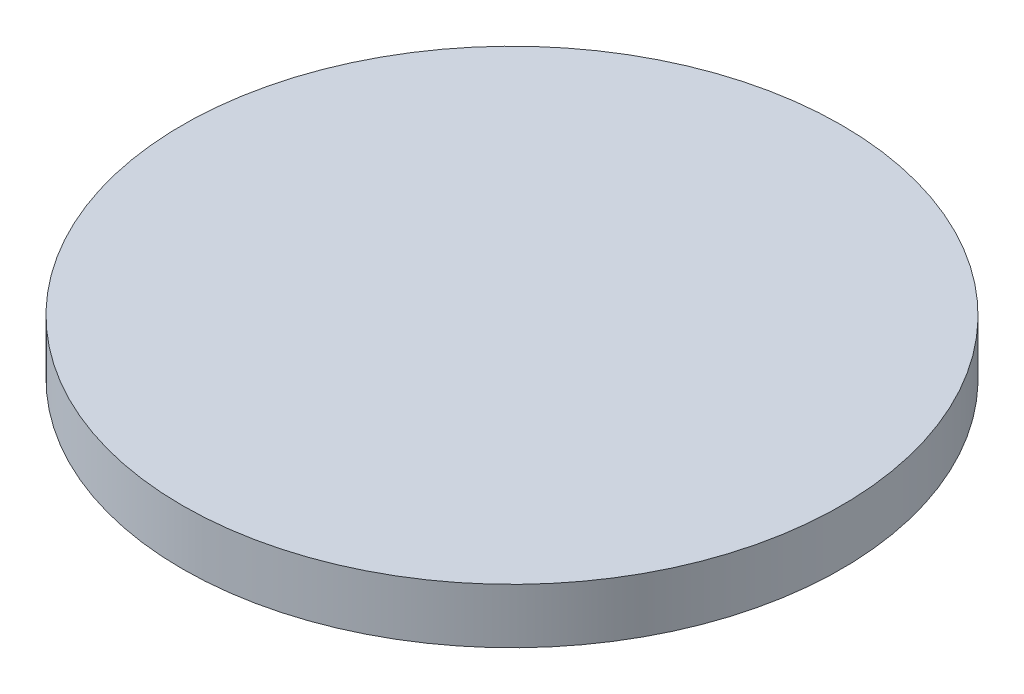
from build123d import *

# Parameters (mm, degrees)
SKETCH1_R           = 38.1
BOSS_EXTRUDE1_DEPTH = 6.35


with BuildPart() as part:
    # Sketch1 → Boss-Extrude1 (new body)
    with BuildSketch(Plane(origin=(0, 0, 0), x_dir=(1, 0, 0), z_dir=(0, 1, 0))):
        Circle(SKETCH1_R)
    extrude(amount=BOSS_EXTRUDE1_DEPTH)


solid = part.part
